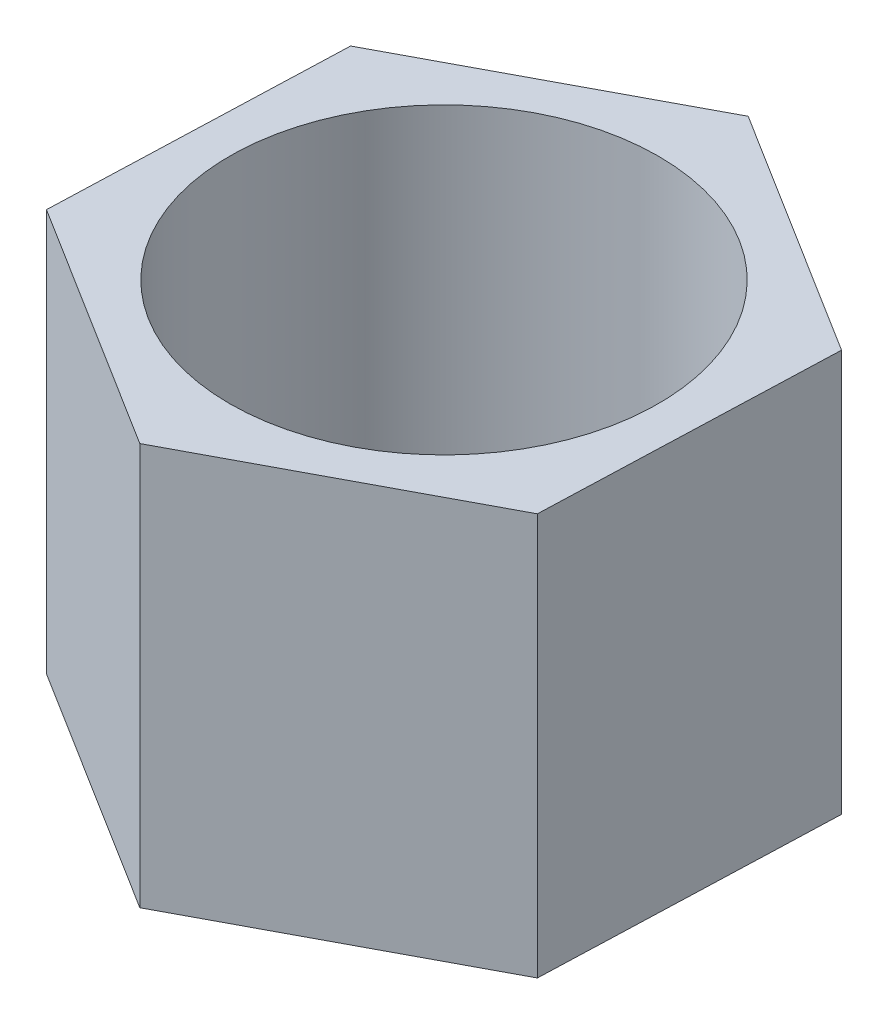
from build123d import *

# Parameters (mm, degrees)
SKETCH1_R           = 8
BOSS_EXTRUDE1_DEPTH = 15


with BuildPart() as part:
    # Sketch1 → Boss-Extrude1 (new body)
    with BuildSketch(Plane(origin=(0, 0, 0), x_dir=(1, 0, 0), z_dir=(0, 1, 0))):
        Polygon((-9.300662228, 5.81644354), (-9.687518979, -5.146387992), (-0.386856751, -10.962831531), (9.300662228, -5.81644354), (9.687518979, 5.146387992), (0.386856751, 10.962831531), align=None)
        Circle(SKETCH1_R, mode=Mode.SUBTRACT)
    extrude(amount=BOSS_EXTRUDE1_DEPTH)


solid = part.part
